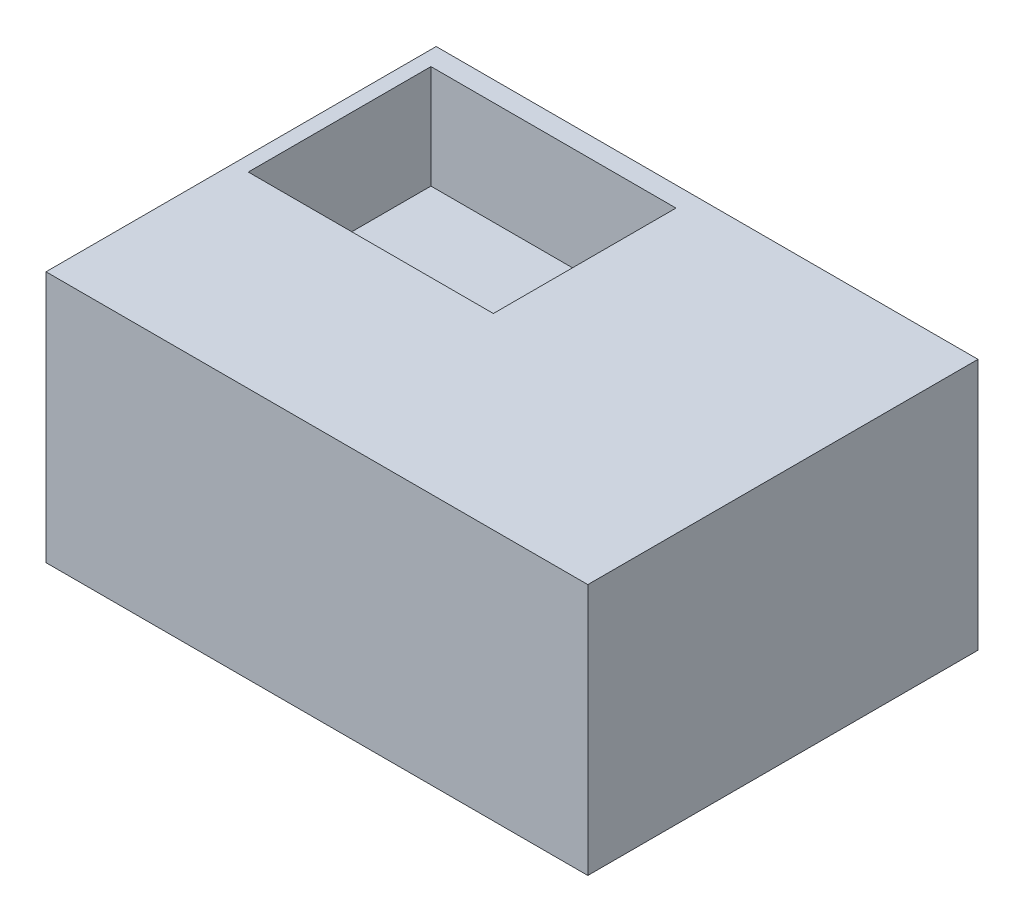
from build123d import *

# Parameters (mm, degrees)
SKETCH1_W           = 120.434130947
SKETCH1_H           = 86.72772323
BOSS_EXTRUDE1_DEPTH = 56
SKETCH2_W           = 54.471409392
SKETCH2_H           = 40.595785154
CUT_EXTRUDE1_DEPTH  = 23


with BuildPart() as part:
    # Sketch1 → Boss-Extrude1 (new body)
    with BuildSketch(Plane(origin=(0, 0, 0), x_dir=(1, 0, 0), z_dir=(0, 1, 0))):
        with Locations((2.461703934, 0)):
            Rectangle(SKETCH1_W, SKETCH1_H)
    extrude(amount=BOSS_EXTRUDE1_DEPTH)

    # Sketch2 → Cut-Extrude1 (cut)
    with BuildSketch(Plane(origin=(0, 56, 0), x_dir=(1, 0, 0), z_dir=(0, 1, 0))):
        with Locations((-27.235704696, 18.614652705)):
            Rectangle(SKETCH2_W, SKETCH2_H)
    extrude(amount=-CUT_EXTRUDE1_DEPTH, mode=Mode.SUBTRACT)


solid = part.part
